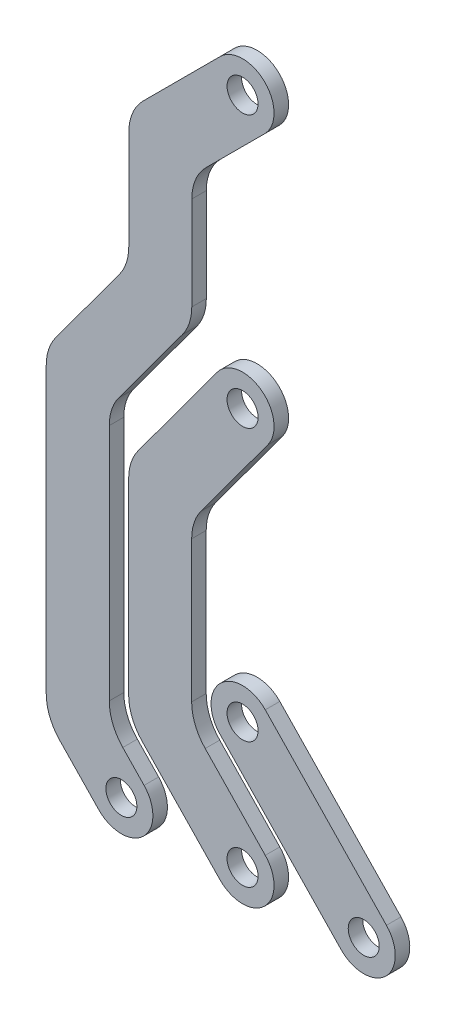
from build123d import *

# Parameters (mm, degrees)
EXTRUDE_1_DEPTH             = 3
EXTRUDE_1_2_DEPTH           = 3
EXTRUDE_1_3_DEPTH           = 3
SKETCH_6_W                  = 3.2
SKETCH_6_H                  = 3
HOLE_WIZARD_M6_1_AT_2_COUNT = 2
HOLE_WIZARD_M6_1_AT_2_PITCH = 25
HOLE_WIZARD_M6_1_AT_3_COUNT = 2
HOLE_WIZARD_M6_1_AT_3_PITCH = 50
HOLE_WIZARD_M6_1_AT_4_COUNT = 2
HOLE_WIZARD_M6_1_AT_4_PITCH = 85.726308681
HOLE_WIZARD_M6_1_AT_5_COUNT = 2
HOLE_WIZARD_M6_1_AT_5_PITCH = 36.069377594
HOLE_WIZARD_M6_1_AT_6_COUNT = 2
HOLE_WIZARD_M6_1_AT_6_PITCH = 140.24621207
FILLET_1_R                  = 10
FILLET_2_R                  = 10
SKETCH_7_R                  = 3.2
CUT_EXTRUDE_1_DEPTH         = 10
SKETCH_7_3_R                = 3.2
EXTRUDE_2_DEPTH             = 3
FILLET_3_R                  = 10


with BuildPart() as part:
    # 草图4 → 凸台-拉伸1 (new body)
    with BuildSketch(Plane.XY):
        with BuildLine():
            Line((-33.086531987, -357.221961826), (-25.901117065, -364.694793344))
            ThreePointArc((-25.901117065, -364.694793344), (-26.081325331, -373.885414922), (-35.271946908, -373.705206656))
            Line((-35.271946908, -373.705206656), (-46.086531987, -362.458038174))
            Line((-46.086531987, -362.458038174), (-46.086531987, -296.462680507))
            Line((-46.086531987, -296.462680507), (-12.086531987, -250.228047376))
            Line((-12.086531987, -250.228047376), (-12.086531987, -231.2))
            ThreePointArc((-12.086531987, -231.2), (-5.586531987, -224.7), (0.913468013, -231.2))
            Line((0.913468013, -231.2), (0.913468013, -254.493431981))
            Line((0.913468013, -254.493431981), (-33.086531987, -300.728065112))
            Line((-33.086531987, -300.728065112), (-33.086531987, -357.221961826))
        make_face()
    extrude(amount=EXTRUDE_1_DEPTH)


with BuildPart() as body_2:
    # 草图4 → Extrude 1 2 (new body)
    with BuildSketch(Plane.XY):
        with BuildLine():
            Line((-10.82305025, -283.349171976), (-29.086531987, -308.184624263))
            Line((-29.086531987, -308.184624263), (-29.086531987, -354.138038174))
            Line((-29.086531987, -354.138038174), (-10.271946908, -373.705206656))
            ThreePointArc((-10.271946908, -373.705206656), (-1.081325331, -373.885414922), (-0.901117065, -364.694793344))
            Line((-0.901117065, -364.694793344), (-16.086531987, -348.901961826))
            Line((-16.086531987, -348.901961826), (-16.086531987, -312.450008868))
            Line((-16.086531987, -312.450008868), (-0.350013723, -291.050828024))
            ThreePointArc((-0.350013723, -291.050828024), (-1.735703962, -281.963481736), (-10.82305025, -283.349171976))
        make_face()
    extrude(amount=EXTRUDE_1_2_DEPTH)


with BuildPart() as body_3:
    # 草图4 → Extrude 1 3 (new body)
    with BuildSketch(Plane.XY):
        with BuildLine():
            Line((-0.901117065, -338.694793344), (24.098882935, -364.694793344))
            ThreePointArc((24.098882935, -364.694793344), (23.918674669, -373.885414922), (14.728053092, -373.705206656))
            Line((14.728053092, -373.705206656), (-10.271946908, -347.705206656))
            ThreePointArc((-10.271946908, -347.705206656), (-10.091738642, -338.514585078), (-0.901117065, -338.694793344))
        make_face()
    extrude(amount=EXTRUDE_1_3_DEPTH)

    # 草图6 → M6 间隙孔1 (revolve, cut)
    with BuildSketch(Plane(origin=(19.413468013, -369.2, 0), x_dir=(0, 1, 0), z_dir=(1, 0, 0))):
        with Locations((1.6, 1.5)):
            Rectangle(SKETCH_6_W, SKETCH_6_H)
    hole_wizard_m6_1 = revolve(axis=Axis((19.413468013, -369.2, -6.35), (0, 0, 1)), mode=Mode.SUBTRACT)

    # M6 间隙孔1 at 5: M6 间隙孔1 ×2
    with Locations(*[Vector(-0.693108716, 0.720833065, 0) * (i * HOLE_WIZARD_M6_1_AT_5_PITCH) for i in range(1, HOLE_WIZARD_M6_1_AT_5_COUNT)]):
        add(hole_wizard_m6_1, mode=Mode.SUBTRACT)


with BuildPart() as body_2_1:
    add(body_2.part)

    # M6 间隙孔1 at 2: M6 间隙孔1 ×2
    with Locations(*[(-i * HOLE_WIZARD_M6_1_AT_2_PITCH, 0, 0) for i in range(1, HOLE_WIZARD_M6_1_AT_2_COUNT)]):
        add(hole_wizard_m6_1, mode=Mode.SUBTRACT)

    # M6 间隙孔1 at 4: M6 间隙孔1 ×2
    with Locations(*[Vector(-0.291625761, 0.956532496, 0) * (i * HOLE_WIZARD_M6_1_AT_4_PITCH) for i in range(1, HOLE_WIZARD_M6_1_AT_4_COUNT)]):
        add(hole_wizard_m6_1, mode=Mode.SUBTRACT)

    # 圆角1
    fillet_1_edges = [body_2_1.edges().sort_by_distance(p)[0] for p in [
        (-16.086531987, -312.450008868, 1.5),
        (-16.086531987, -348.901961826, 1.5),
        (-29.086531987, -354.138038174, 1.5),
        (-29.086531987, -308.184624263, 1.5),
    ]]
    fillet(fillet_1_edges, radius=FILLET_1_R)


with BuildPart() as part_1:
    add(part.part)

    # M6 间隙孔1 at 3: M6 间隙孔1 ×2
    with Locations(*[(-i * HOLE_WIZARD_M6_1_AT_3_PITCH, 0, 0) for i in range(1, HOLE_WIZARD_M6_1_AT_3_COUNT)]):
        add(hole_wizard_m6_1, mode=Mode.SUBTRACT)

    # M6 间隙孔1 at 6: M6 间隙孔1 ×2
    with Locations(*[Vector(-0.178257934, 0.983983795, 0) * (i * HOLE_WIZARD_M6_1_AT_6_PITCH) for i in range(1, HOLE_WIZARD_M6_1_AT_6_COUNT)]):
        add(hole_wizard_m6_1, mode=Mode.SUBTRACT)

    # 圆角2
    fillet_2_edges = [part_1.edges().sort_by_distance(p)[0] for p in [
        (-33.086531987, -357.221961826, 1.5),
        (-46.086531987, -362.458038174, 1.5),
        (-46.086531987, -296.462680507, 1.5),
        (-12.086531987, -250.228047376, 1.5),
        (0.913468013, -254.493431981, 1.5),
        (-33.086531987, -300.728065112, 1.5),
    ]]
    fillet(fillet_2_edges, radius=FILLET_2_R)

    # 草图7 → 切除-拉伸1 (cut)
    with BuildSketch(Plane(origin=(0, 0, 0), x_dir=(-1, 0, 0), z_dir=(0, 0, -1))):
        with BuildLine():
            Line((1.030350042, -257.136717707), (16.061662492, -277.576929959))
            Line((16.061662492, -277.576929959), (16.061662492, -255.633597392))
            Line((16.061662492, -255.633597392), (14.030350042, -252.871333102))
            ThreePointArc((14.030350042, -252.871333102), (12.584905298, -250.064527848), (12.086531987, -246.946982295))
            Line((12.086531987, -246.946982295), (12.086531987, -246.892388155))
            Line((12.086531987, -246.892388155), (0.990337909, -235.796194078))
            ThreePointArc((0.990337909, -235.796194078), (-0.418684975, -233.68744231), (-0.913468013, -231.2))
            Line((-0.913468013, -231.2), (-0.913468013, -251.2123669))
            ThreePointArc((-0.913468013, -251.2123669), (-0.415094702, -254.329912453), (1.030350042, -257.136717707))
        make_face()
        with BuildLine():
            Line((0.990337909, -235.796194078), (12.086531987, -246.892388155))
            Line((12.086531987, -246.892388155), (12.086531987, -231.2))
            ThreePointArc((12.086531987, -231.2), (8.073974297, -237.205216961), (0.990337909, -235.796194078))
        make_face()
        with BuildLine():
            ThreePointArc((10.182726064, -226.603805922), (3.099089676, -225.194783039), (-0.913468013, -231.2))
            ThreePointArc((-0.913468013, -231.2), (-0.418684975, -233.68744231), (0.990337909, -235.796194078))
            ThreePointArc((0.990337909, -235.796194078), (8.073974297, -237.205216961), (12.086531987, -231.2))
            ThreePointArc((12.086531987, -231.2), (11.591748948, -228.71255769), (10.182726064, -226.603805922))
        make_face()
        with Locations((5.586531987, -231.2)):
            Circle(SKETCH_7_R, mode=Mode.SUBTRACT)
    extrude(amount=-CUT_EXTRUDE_1_DEPTH, mode=Mode.SUBTRACT)

    # 草图7<3> → 凸台-拉伸2 (add)
    with BuildSketch(Plane(origin=(0, 0, 0), x_dir=(-1, 0, 0), z_dir=(0, 0, -1))):
        with BuildLine():
            Line((16.061662492, -250.867518661), (16.061662492, -255.633597392))
            Line((16.061662492, -255.633597392), (29.061662492, -273.311545354))
            Line((29.061662492, -273.311545354), (29.061662492, -245.48274235))
            Line((29.061662492, -245.48274235), (10.182726064, -226.603805922))
            ThreePointArc((10.182726064, -226.603805922), (0.990337909, -226.603805922), (0.990337909, -235.796194078))
            Line((0.990337909, -235.796194078), (16.061662492, -250.867518661))
        make_face()
        with Locations((5.586531987, -231.2)):
            Circle(SKETCH_7_3_R, mode=Mode.SUBTRACT)
    extrude(amount=-EXTRUDE_2_DEPTH)

    # 圆角3
    fillet_3_edges = [part_1.edges().sort_by_distance(p)[0] for p in [
        (-16.061662492, -250.867518661, 1.5),
        (-29.061662492, -273.311545354, 1.5),
        (-29.061662492, -245.48274235, 1.5),
        (-16.061662492, -277.576929959, 1.5),
    ]]
    fillet(fillet_3_edges, radius=FILLET_3_R)


solid = Compound([body_3.part, body_2_1.part, part_1.part])
